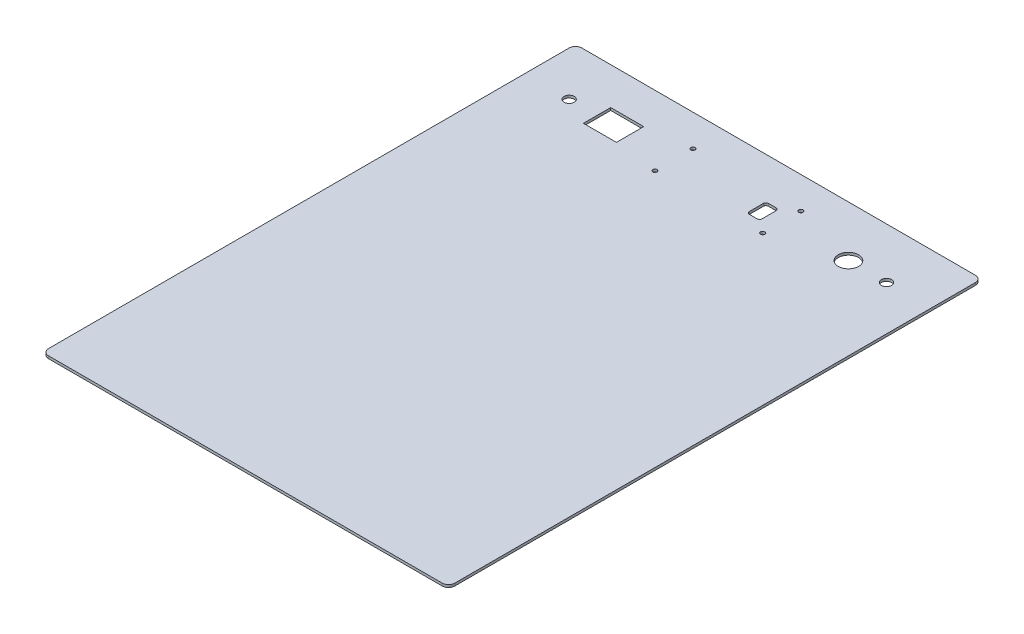
from build123d import *

# Parameters (mm, degrees)
SKETCH1_W           = 320
SKETCH1_H           = 420
BOSS_EXTRUDE1_DEPTH = 2
SKETCH3_R           = 1.7
SKETCH3_W           = 10
SKETCH3_H           = 15
CUT_EXTRUDE1_DEPTH  = 2
SKETCH5_R           = 4
SKETCH5_R_2         = 8
SKETCH5_W           = 26
SKETCH5_H           = 21.5
CUT_EXTRUDE2_DEPTH  = 2
FILLET1_R           = 5
FILLET2_R           = 2


with BuildPart() as part:
    # Sketch1 → Boss-Extrude1 (new body)
    with BuildSketch(Plane(origin=(0, 0, 0), x_dir=(1, 0, 0), z_dir=(0, 1, 0))):
        Rectangle(SKETCH1_W, SKETCH1_H)
    extrude(amount=BOSS_EXTRUDE1_DEPTH)

    # Sketch3 → Cut-Extrude1 (cut)
    with BuildSketch(Plane(origin=(0, 2, 0), x_dir=(1, 0, 0), z_dir=(0, 1, 0))):
        with Locations((-42.5, 185)):
            Circle(SKETCH3_R)
        with Locations((42.5, 185)):
            Circle(SKETCH3_R)
        with Locations((42.5, 155)):
            Circle(SKETCH3_R)
        with Locations((-42.5, 155)):
            Circle(SKETCH3_R)
        with Locations((27.5, 170)):
            Rectangle(SKETCH3_W, SKETCH3_H)
    extrude(amount=-CUT_EXTRUDE1_DEPTH, mode=Mode.SUBTRACT)

    # Sketch5 → Cut-Extrude2 (cut)
    with BuildSketch(Plane(origin=(0, 2, 0), x_dir=(1, 0, 0), z_dir=(0, 1, 0))):
        with Locations((-125, 170)):
            Circle(SKETCH5_R)
        with Locations((95, 170)):
            Circle(SKETCH5_R_2)
        with Locations((125, 170)):
            Circle(SKETCH5_R)
        with Locations((-90, 170)):
            Rectangle(SKETCH5_W, SKETCH5_H)
    extrude(amount=-CUT_EXTRUDE2_DEPTH, mode=Mode.SUBTRACT)

    # Fillet1
    fillet1_edges = [part.edges().sort_by_distance(p)[0] for p in [
        (160, 1, 210),
        (-160, 1, 210),
        (-160, 1, -210),
        (160, 1, -210),
    ]]
    fillet(fillet1_edges, radius=FILLET1_R)

    # Fillet2
    fillet2_edges = [part.edges().sort_by_distance(p)[0] for p in [
        (32.5, 1, -162.5),
        (22.5, 1, -162.5),
        (22.5, 1, -177.5),
        (32.5, 1, -177.5),
    ]]
    fillet(fillet2_edges, radius=FILLET2_R)


solid = part.part
